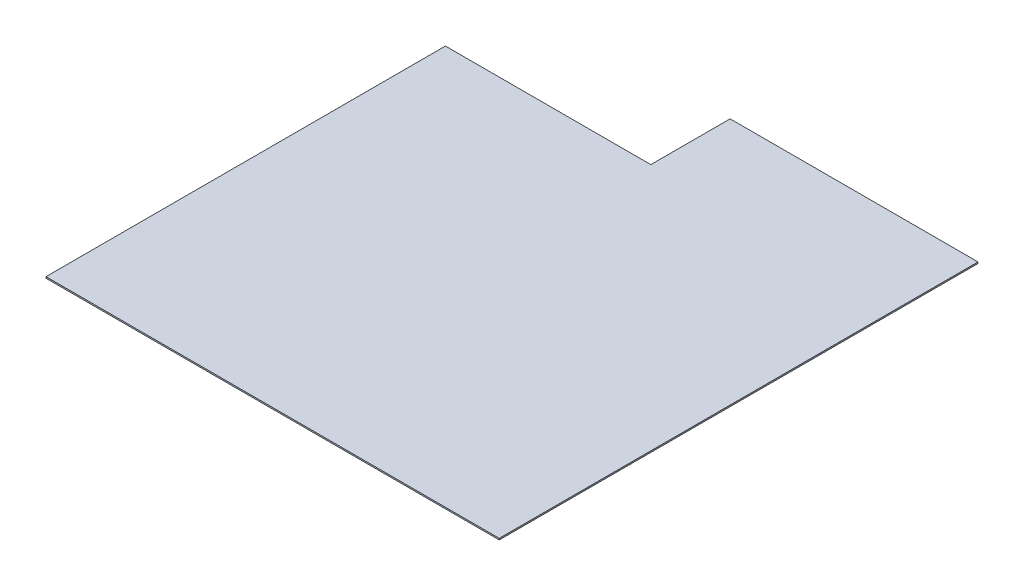
from build123d import *

# Parameters (mm, degrees)
BOSS_EXTRUDE1_DEPTH = 3.175


with BuildPart() as part:
    # Sketch1 → Boss-Extrude1 (new body)
    with BuildSketch(Plane(origin=(0, 0, 0), x_dir=(1, 0, 0), z_dir=(0, 1, 0))):
        Polygon((0, 0), (0, 1073.15), (-555.625, 1073.15), (-555.625, 895.35), (-1016, 895.35), (-1016, 0), align=None)
    extrude(amount=BOSS_EXTRUDE1_DEPTH)


solid = part.part
